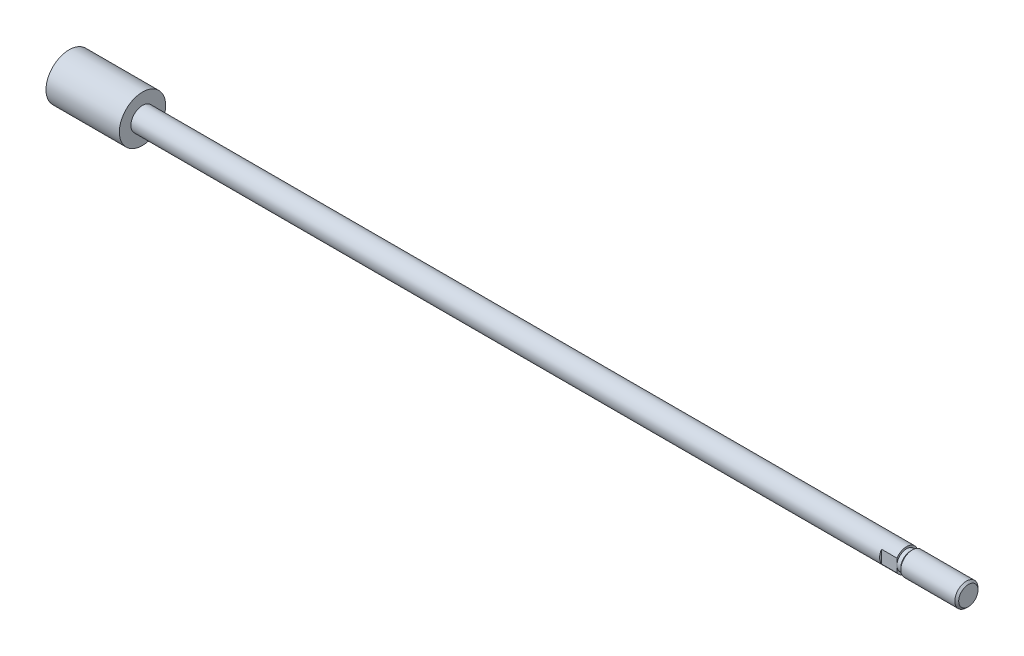
from build123d import *

# Parameters (mm, degrees)
CHAMFER1_SIZE      = 0.5
SKETCH2_W          = 3.5
SKETCH2_H          = 12
CUT_EXTRUDE1_DEPTH = 4


with BuildPart() as part:
    # Sketch1 → Revolve1 (revolve)
    with BuildSketch(Plane.XY):
        Polygon((0, -6), (0, 0), (233, 0), (233, -3), (218.5, -3), (218, -2.5), (217, -2.5), (217, -3), (19, -3), (19, -6), align=None)
    revolve(axis=Axis((-26.391164048, 0, 0), (1, 0, 0)))

    # Chamfer1
    chamfer1_edges = [part.edges().sort_by_distance(p)[0] for p in [
        (233, 3, 0),
    ]]
    chamfer(chamfer1_edges, length=CHAMFER1_SIZE)

    # Sketch2 → Cut-Extrude1 (cut)
    with BuildSketch(Plane(origin=(217, 0, 0), x_dir=(0, 0, -1), z_dir=(1, 0, 0))):
        with Locations((-4.25, 0)):
            Rectangle(SKETCH2_W, SKETCH2_H)
    cut_extrude1 = extrude(amount=-CUT_EXTRUDE1_DEPTH, mode=Mode.SUBTRACT)

    # Mirror1: Cut-Extrude1 across plane
    add(cut_extrude1.mirror(Plane.XY), mode=Mode.SUBTRACT)


solid = part.part
